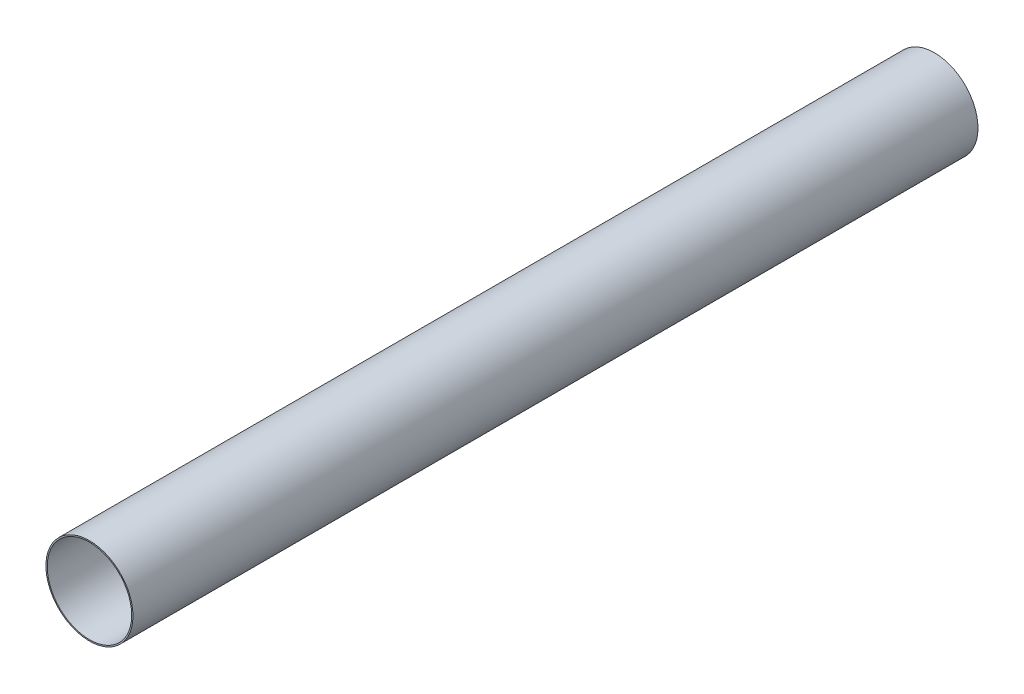
from build123d import *

# Parameters (mm, degrees)
SKETCH1_R           = 39.2557
SKETCH1_R_2         = 38.1
BOSS_EXTRUDE1_DEPTH = 381


with BuildPart() as part:
    # Sketch1 → Boss-Extrude1 (new body, symmetric)
    with BuildSketch(Plane.XY):
        Circle(SKETCH1_R)
        Circle(SKETCH1_R_2, mode=Mode.SUBTRACT)
    extrude(amount=BOSS_EXTRUDE1_DEPTH, both=True)


solid = part.part
